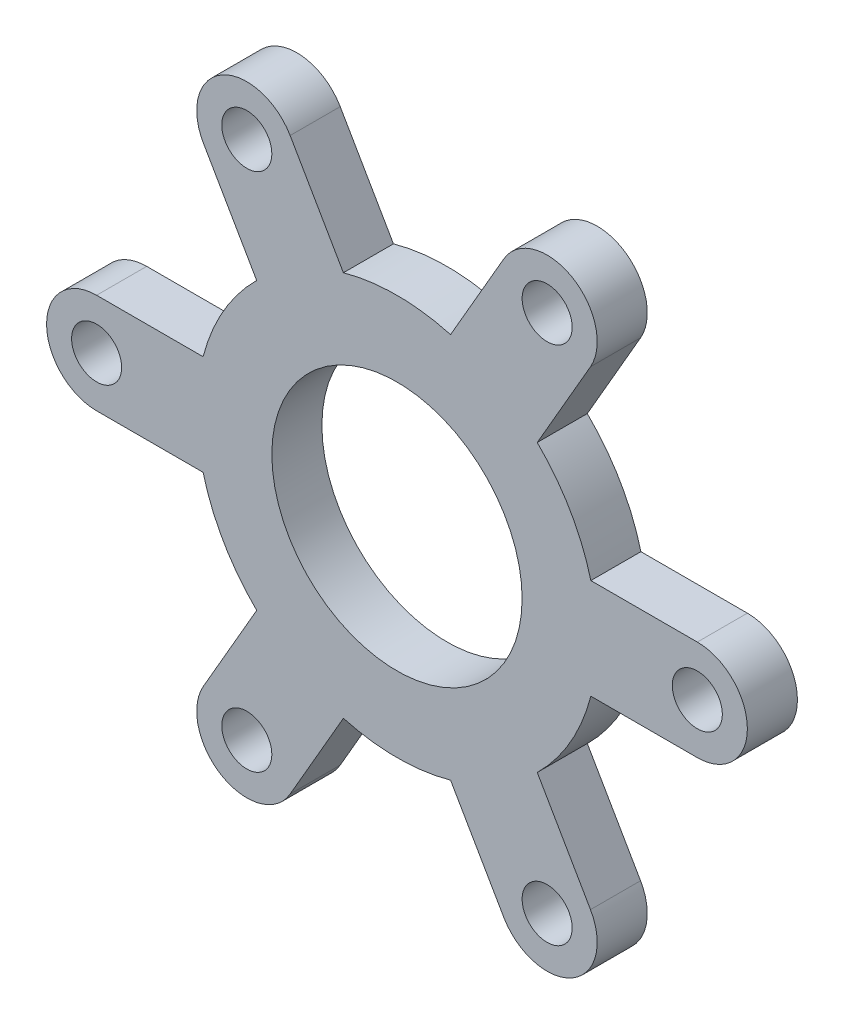
from build123d import *

# Parameters (mm, degrees)
SKETCH1_R           = 5
SKETCH1_R_2         = 25
BOSS_EXTRUDE1_DEPTH = 10


with BuildPart() as part:
    # Sketch1 → Boss-Extrude1 (new body)
    with BuildSketch(Plane.XY):
        with BuildLine():
            Line((60, 10), (38.729833462, 10))
            ThreePointArc((38.729833462, 10), (34.641016151, 20), (28.025170769, 28.541019662))
            Line((28.025170769, 28.541019662), (38.660254038, 46.961524227))
            ThreePointArc((38.660254038, 46.961524227), (35, 60.621778265), (21.339745962, 56.961524227))
            Line((21.339745962, 56.961524227), (10.704662693, 38.541019662))
            ThreePointArc((10.704662693, 38.541019662), (0, 40), (-10.704662693, 38.541019662))
            Line((-10.704662693, 38.541019662), (-21.339745962, 56.961524227))
            ThreePointArc((-21.339745962, 56.961524227), (-35, 60.621778265), (-38.660254038, 46.961524227))
            Line((-38.660254038, 46.961524227), (-28.025170769, 28.541019662))
            ThreePointArc((-28.025170769, 28.541019662), (-34.641016151, 20), (-38.729833462, 10))
            Line((-38.729833462, 10), (-60, 10))
            ThreePointArc((-60, 10), (-70, 0), (-60, -10))
            Line((-60, -10), (-38.729833462, -10))
            ThreePointArc((-38.729833462, -10), (-34.641016151, -20), (-28.025170769, -28.541019662))
            Line((-28.025170769, -28.541019662), (-38.660254038, -46.961524227))
            ThreePointArc((-38.660254038, -46.961524227), (-35, -60.621778265), (-21.339745962, -56.961524227))
            Line((-21.339745962, -56.961524227), (-10.704662693, -38.541019662))
            ThreePointArc((-10.704662693, -38.541019662), (0, -40), (10.704662693, -38.541019662))
            Line((10.704662693, -38.541019662), (21.339745962, -56.961524227))
            ThreePointArc((21.339745962, -56.961524227), (35, -60.621778265), (38.660254038, -46.961524227))
            Line((38.660254038, -46.961524227), (28.025170769, -28.541019662))
            ThreePointArc((28.025170769, -28.541019662), (34.641016151, -20), (38.729833462, -10))
            Line((38.729833462, -10), (60, -10))
            ThreePointArc((60, -10), (70, 0), (60, 10))
        make_face()
        with Locations((60, 0)):
            Circle(SKETCH1_R, mode=Mode.SUBTRACT)
        with Locations((30, -51.961524227)):
            Circle(SKETCH1_R, mode=Mode.SUBTRACT)
        with Locations((-30, -51.961524227)):
            Circle(SKETCH1_R, mode=Mode.SUBTRACT)
        with Locations((-60, 0)):
            Circle(SKETCH1_R, mode=Mode.SUBTRACT)
        with Locations((-30, 51.961524227)):
            Circle(SKETCH1_R, mode=Mode.SUBTRACT)
        with Locations((30, 51.961524227)):
            Circle(SKETCH1_R, mode=Mode.SUBTRACT)
        Circle(SKETCH1_R_2, mode=Mode.SUBTRACT)
    extrude(amount=BOSS_EXTRUDE1_DEPTH)


solid = part.part
